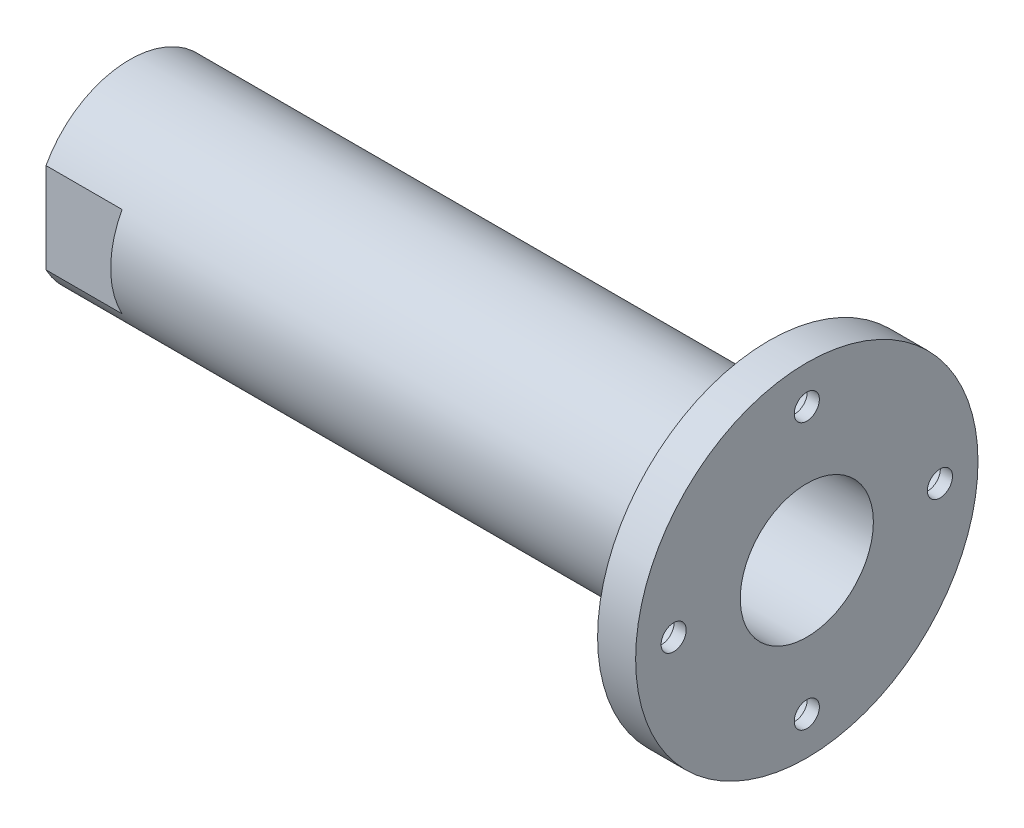
from build123d import *

# Parameters (mm, degrees)
SKETCH_1_W                = 178
SKETCH_1_H                = 25
SKETCH_6_OUTSIDE_W        = 90.306
SKETCH_6_OUTSIDE_H        = 90.306
SKETCH_6_OUTSIDE_W_2      = 44
SKETCH_6_OUTSIDE_H_2      = 60
CUT_EXTRUDE_1_DEPTH       = 20
M26X1_5_2_D               = 23.5
SKETCH_10_R               = 45
SKETCH_10_R_2             = 25
EXTRUDE_1_DEPTH           = 10
HOLE_WIZARD_1_D           = 6.6
HOLE_WIZARD_1_CBORE_D     = 11
HOLE_WIZARD_1_CBORE_DEPTH = 6.8
PATTERN_CIRCULAR_1_COUNT  = 4
SKETCH_14_R               = 17.5
CUT_EXTRUDE_2_DEPTH       = 120


with BuildPart() as part:
    # 草图1 → 旋转1 (revolve)
    with BuildSketch(Plane.XY):
        with Locations((89, 12.5)):
            Rectangle(SKETCH_1_W, SKETCH_1_H)
    revolve(axis=Axis((-8.837336018, 0, 0), (1, 0, 0)))

    # 草图6 outside → 切除-拉伸1 (cut)
    with BuildSketch(Plane.ZY):
        Rectangle(SKETCH_6_OUTSIDE_W, SKETCH_6_OUTSIDE_H)
        Rectangle(SKETCH_6_OUTSIDE_W_2, SKETCH_6_OUTSIDE_H_2, mode=Mode.SUBTRACT)
    extrude(amount=-CUT_EXTRUDE_1_DEPTH, mode=Mode.SUBTRACT)

    # M26x1.5螺纹孔2 (through all)
    with Locations(Plane.ZY):
        with Locations((0, 0)):
            Hole(M26X1_5_2_D / 2)

    # 草图10 → 凸台-拉伸1 (add)
    with BuildSketch(Plane(origin=(178, 0, 0), x_dir=(0, 0, -1), z_dir=(1, 0, 0))):
        Circle(SKETCH_10_R)
        Circle(SKETCH_10_R_2, mode=Mode.SUBTRACT)
    extrude(amount=-EXTRUDE_1_DEPTH)

    # 打孔尺寸(%根据)内六角圆柱头螺钉的类型1 (through all)
    with Locations(Plane(origin=(168, 35, 0), x_dir=(0, 0, -1), z_dir=(-1, 0, 0))):
        with Locations((0, 0)):
            hole_wizard_1 = CounterBoreHole(HOLE_WIZARD_1_D / 2, HOLE_WIZARD_1_CBORE_D / 2, HOLE_WIZARD_1_CBORE_DEPTH)

    # 阵列(圆周)1: 打孔尺寸(%根据)内六角圆柱头螺钉的类型1 ×4 about axis
    pattern_circular_1_axis = Axis((0, 0, 0), (1, 0, 0))
    for i in range(1, PATTERN_CIRCULAR_1_COUNT):
        add(hole_wizard_1.rotate(pattern_circular_1_axis, i * 360 / PATTERN_CIRCULAR_1_COUNT), mode=Mode.SUBTRACT)

    # 草图14 → 切除-拉伸2 (cut)
    with BuildSketch(Plane(origin=(178, 0, 0), x_dir=(0, 0, -1), z_dir=(1, 0, 0))):
        Circle(SKETCH_14_R)
    extrude(amount=-CUT_EXTRUDE_2_DEPTH, mode=Mode.SUBTRACT)


solid = part.part
